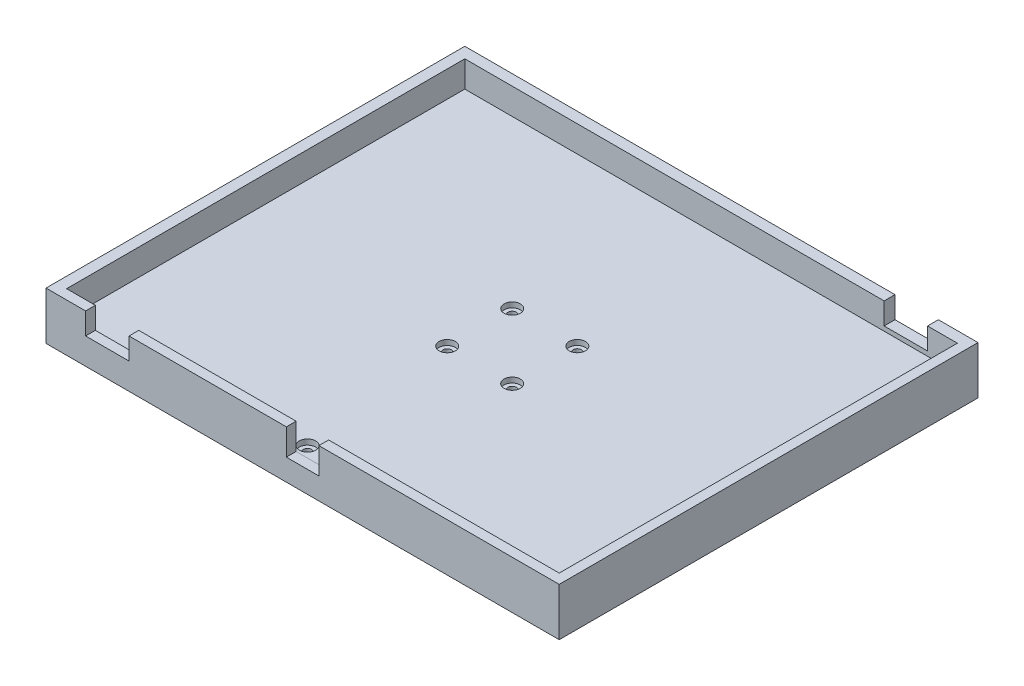
from build123d import *

# Parameters (mm, degrees)
SKETCH2_W                = 236.5
SKETCH2_H                = 193
SKETCH2_W_2              = 227
SKETCH2_H_2              = 183.5
BOSS_EXTRUDE1_DEPTH      = 12.1
SKETCH3_W                = 236.5
SKETCH3_H                = 193
BOSS_EXTRUDE2_DEPTH      = 10
SKETCH4_W                = 10
SKETCH4_H                = 10
CUT_EXTRUDE1_DEPTH       = 5
SKETCH7_W                = 20
SKETCH7_H                = 10
CUT_EXTRUDE2_DEPTH       = 5
SKETCH8_W                = 20
SKETCH8_H                = 10
CUT_EXTRUDE3_DEPTH       = 5
SKETCH32_W               = 20
SKETCH32_H               = 12.1
CUT_EXTRUDE14_DEPTH      = 6
SKETCH34_R               = 1.925
CUT_EXTRUDE16_DEPTH      = 11
SKETCH35_R               = 3.75
SKETCH35_R_2             = 1.925
CUT_EXTRUDE17_DEPTH      = 2.4
SKETCH36_W               = 20
SKETCH36_H               = 12.1
BOSS_EXTRUDE9_DEPTH      = 5
SKETCH37_W               = 15
SKETCH37_H               = 12.1
CUT_EXTRUDE18_DEPTH      = 5
SKETCH44_R               = 1.925
CUT_EXTRUDE21_DEPTH      = 13.1
CUT_EXTRUDE21_DEPTH_BACK = 11
SKETCH44_4_R             = 3.75
CUT_EXTRUDE22_DEPTH      = 2.5
SKETCH47_R               = 3.75
SKETCH47_R_2             = 1.925
CUT_EXTRUDE23_DEPTH      = 2.5
SKETCH47_2_R             = 1.925
CUT_EXTRUDE24_DEPTH      = 11


with BuildPart() as part:
    # Sketch2 → Boss-Extrude1 (new body)
    with BuildSketch(Plane(origin=(0, 0, 0), x_dir=(1, 0, 0), z_dir=(0, 1, 0))):
        with Locations((113.25, -91.5)):
            Rectangle(SKETCH2_W, SKETCH2_H)
        with Locations((113.5, -91.75)):
            Rectangle(SKETCH2_W_2, SKETCH2_H_2, mode=Mode.SUBTRACT)
    extrude(amount=BOSS_EXTRUDE1_DEPTH)

    # Sketch3 → Boss-Extrude2 (add)
    with BuildSketch(Plane.XZ):
        with Locations((113.25, 91.5)):
            Rectangle(SKETCH3_W, SKETCH3_H)
    extrude(amount=BOSS_EXTRUDE2_DEPTH)

    # Sketch4 → Cut-Extrude1 (cut)
    with BuildSketch(Plane.ZY.offset(5)):
        with Locations((96.5, 7.1)):
            Rectangle(SKETCH4_W, SKETCH4_H)
        with Locations((86.5, 7.1)):
            Rectangle(SKETCH4_W, SKETCH4_H)
    extrude(amount=-CUT_EXTRUDE1_DEPTH, mode=Mode.SUBTRACT)

    # Sketch7 → Cut-Extrude2 (cut)
    with BuildSketch(Plane.XY.offset(188)):
        with Locations((23.25, 7.1)):
            Rectangle(SKETCH7_W, SKETCH7_H)
    extrude(amount=-CUT_EXTRUDE2_DEPTH, mode=Mode.SUBTRACT)

    # Sketch8 → Cut-Extrude3 (cut)
    with BuildSketch(Plane(origin=(0, 0, -5), x_dir=(-1, 0, 0), z_dir=(0, 0, -1))):
        with Locations((-203.25, 7.1)):
            Rectangle(SKETCH8_W, SKETCH8_H)
    extrude(amount=-CUT_EXTRUDE3_DEPTH, mode=Mode.SUBTRACT)

    # Sketch32 → Cut-Extrude14 (cut, through all)
    with BuildSketch(Plane(origin=(0, 0, 0), x_dir=(0, 0, -1), z_dir=(1, 0, 0))):
        with Locations((-91.5, 6.05)):
            Rectangle(SKETCH32_W, SKETCH32_H)
    extrude(amount=-CUT_EXTRUDE14_DEPTH, mode=Mode.SUBTRACT)

    # Sketch34 → Cut-Extrude16 (cut, through all)
    with BuildSketch(Plane(origin=(0, 0, 0), x_dir=(1, 0, 0), z_dir=(0, 1, 0))):
        with Locations((128.5, -76.64384905)):
            Circle(SKETCH34_R)
        with Locations((128.467672433, -106.643831632)):
            Circle(SKETCH34_R)
        with Locations((98.532327567, -106.643831632)):
            Circle(SKETCH34_R)
        with Locations((98.5, -76.64384905)):
            Circle(SKETCH34_R)
    extrude(amount=-CUT_EXTRUDE16_DEPTH, mode=Mode.SUBTRACT)

    # Sketch35 → Cut-Extrude17 (cut)
    with BuildSketch(Plane(origin=(0, 0, 0), x_dir=(1, 0, 0), z_dir=(0, 1, 0))):
        with Locations((98.5, -76.64384905)):
            Circle(SKETCH35_R)
        with Locations((98.5, -76.64384905)):
            Circle(SKETCH35_R_2, mode=Mode.SUBTRACT)
        with Locations((128.5, -76.64384905)):
            Circle(SKETCH35_R)
        with Locations((128.5, -76.64384905)):
            Circle(SKETCH35_R_2, mode=Mode.SUBTRACT)
        with Locations((98.532327567, -106.643831632)):
            Circle(SKETCH35_R)
        with Locations((98.532327567, -106.643831632)):
            Circle(SKETCH35_R_2, mode=Mode.SUBTRACT)
        with Locations((128.467672433, -106.643831632)):
            Circle(SKETCH35_R)
    extrude(amount=-CUT_EXTRUDE17_DEPTH, mode=Mode.SUBTRACT)

    # Sketch36 → Boss-Extrude9 (add)
    with BuildSketch(Plane(origin=(0, 0, 0), x_dir=(0, 0, -1), z_dir=(1, 0, 0))):
        with Locations((-91.5, 6.05)):
            Rectangle(SKETCH36_W, SKETCH36_H)
    extrude(amount=-BOSS_EXTRUDE9_DEPTH)

    # Sketch37 → Cut-Extrude18 (cut)
    with BuildSketch(Plane.XY.offset(188)):
        with Locations((113.25, 6.0501)):
            Rectangle(SKETCH37_W, SKETCH37_H)
    extrude(amount=-CUT_EXTRUDE18_DEPTH, mode=Mode.SUBTRACT)

    # Sketch44 → Cut-Extrude21 (cut, two sides)
    with BuildSketch(Plane(origin=(0, 0, 0), x_dir=(1, 0, 0), z_dir=(0, 1, 0))) as cut_extrude21_sk:
        with Locations((121, -178.5)):
            Circle(SKETCH44_R)
        with Locations((106, -178.5)):
            Circle(SKETCH44_R)
    extrude(amount=CUT_EXTRUDE21_DEPTH, mode=Mode.SUBTRACT)
    extrude(cut_extrude21_sk.sketch, amount=-CUT_EXTRUDE21_DEPTH_BACK, mode=Mode.SUBTRACT)

    # Sketch44_4 → Cut-Extrude22 (cut)
    with BuildSketch(Plane(origin=(0, 0, 0), x_dir=(1, 0, 0), z_dir=(0, 1, 0))):
        with Locations((121, -178.5)):
            Circle(SKETCH44_4_R)
        with Locations((106, -178.5)):
            Circle(SKETCH44_4_R)
    extrude(amount=-CUT_EXTRUDE22_DEPTH, mode=Mode.SUBTRACT)

    # Sketch47 → Cut-Extrude23 (cut)
    with BuildSketch(Plane(origin=(0, 0, 0), x_dir=(1, 0, 0), z_dir=(0, 1, 0))):
        with Locations((222, -84.25)):
            Circle(SKETCH47_R)
        with Locations((222, -84.25)):
            Circle(SKETCH47_R_2, mode=Mode.SUBTRACT)
        with Locations((222, -99.25)):
            Circle(SKETCH47_R)
        with Locations((222, -99.25)):
            Circle(SKETCH47_R_2, mode=Mode.SUBTRACT)
    extrude(amount=-CUT_EXTRUDE23_DEPTH, mode=Mode.SUBTRACT)

    # Sketch47_2 → Cut-Extrude24 (cut, through all)
    with BuildSketch(Plane(origin=(0, 0, 0), x_dir=(1, 0, 0), z_dir=(0, 1, 0))):
        with Locations((222, -84.25)):
            Circle(SKETCH47_2_R)
        with Locations((222, -99.25)):
            Circle(SKETCH47_2_R)
    extrude(amount=-CUT_EXTRUDE24_DEPTH, mode=Mode.SUBTRACT)


solid = part.part
